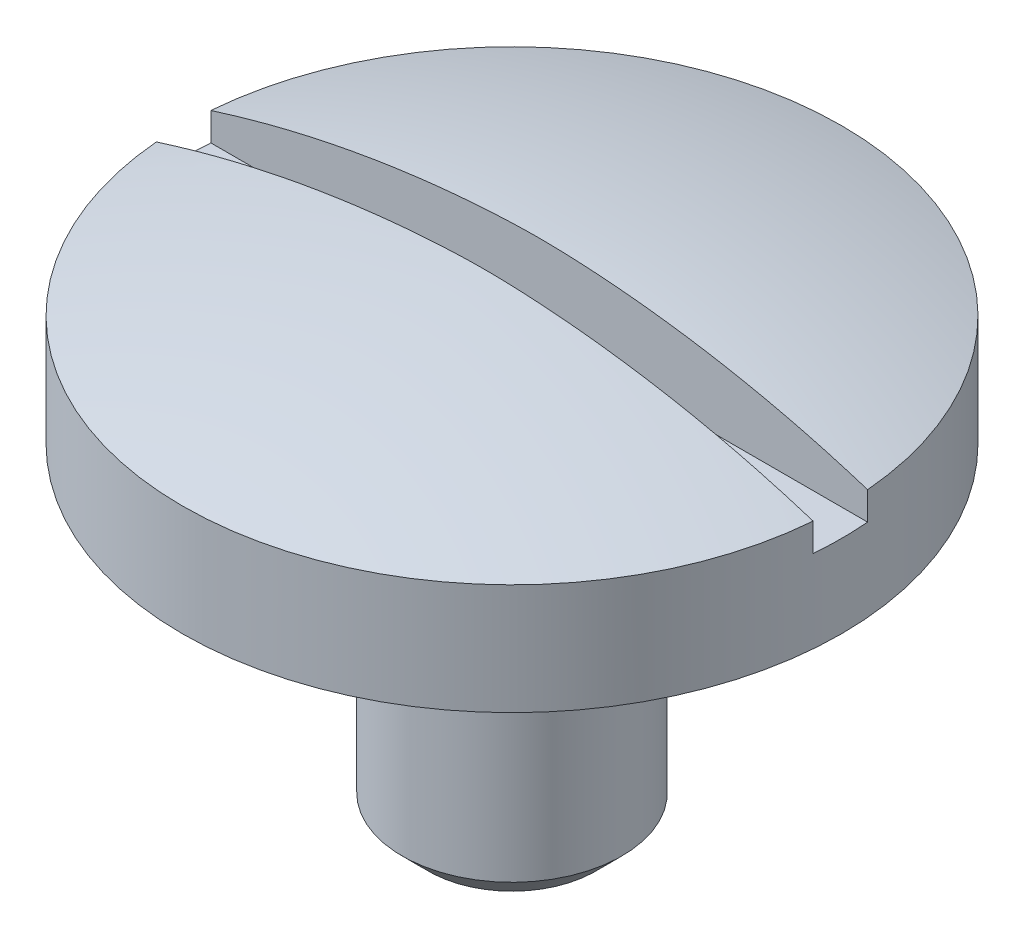
from build123d import *

# Parameters (mm, degrees)
CUT_EXTRUDE4_DEPTH      = 10.5250001
CUT_EXTRUDE4_DEPTH_BACK = 10.5250001
CHAMFER1_SIZE           = 0.762


with BuildPart() as part:
    # Sketch1 → Revolve1 (revolve)
    with BuildSketch(Plane(origin=(0, 0, 0), x_dir=(0, 0, -1), z_dir=(1, 0, 0))):
        with BuildLine():
            Line((0, 0), (3.175, 0))
            Line((3.175, 0), (3.175, 9.4996))
            Line((3.175, 9.4996), (9.525, 9.4996))
            Line((9.525, 9.4996), (9.525, 12.7))
            ThreePointArc((9.525, 12.7), (4.820045897, 13.835459863), (0, 14.2748))
            Line((0, 14.2748), (0, 0))
        make_face()
    revolve(axis=Axis((0, 0, 0), (0, 1, 0)))

    # Sketch2 → Cut-Extrude4 (cut, two sides)
    with BuildSketch(Plane(origin=(0, 0, 0), x_dir=(0, 0, -1), z_dir=(1, 0, 0))) as cut_extrude4_sk:
        Polygon((-0.7874, 59.433466129), (-0.7874, 14.251322907), (-0.7874, 11.8872), (0.7874, 11.8872), (0.7874, 14.251322907), (0.7874, 59.433466129), (0.7874, 149.797752573), (-0.7874, 149.797752573), align=None)
    extrude(amount=CUT_EXTRUDE4_DEPTH, mode=Mode.SUBTRACT)
    extrude(cut_extrude4_sk.sketch, amount=-CUT_EXTRUDE4_DEPTH_BACK, mode=Mode.SUBTRACT)

    # Chamfer1
    chamfer1_edges = [part.edges().sort_by_distance(p)[0] for p in [
        (0, 0, 3.175),
    ]]
    chamfer(chamfer1_edges, length=CHAMFER1_SIZE)


solid = part.part
